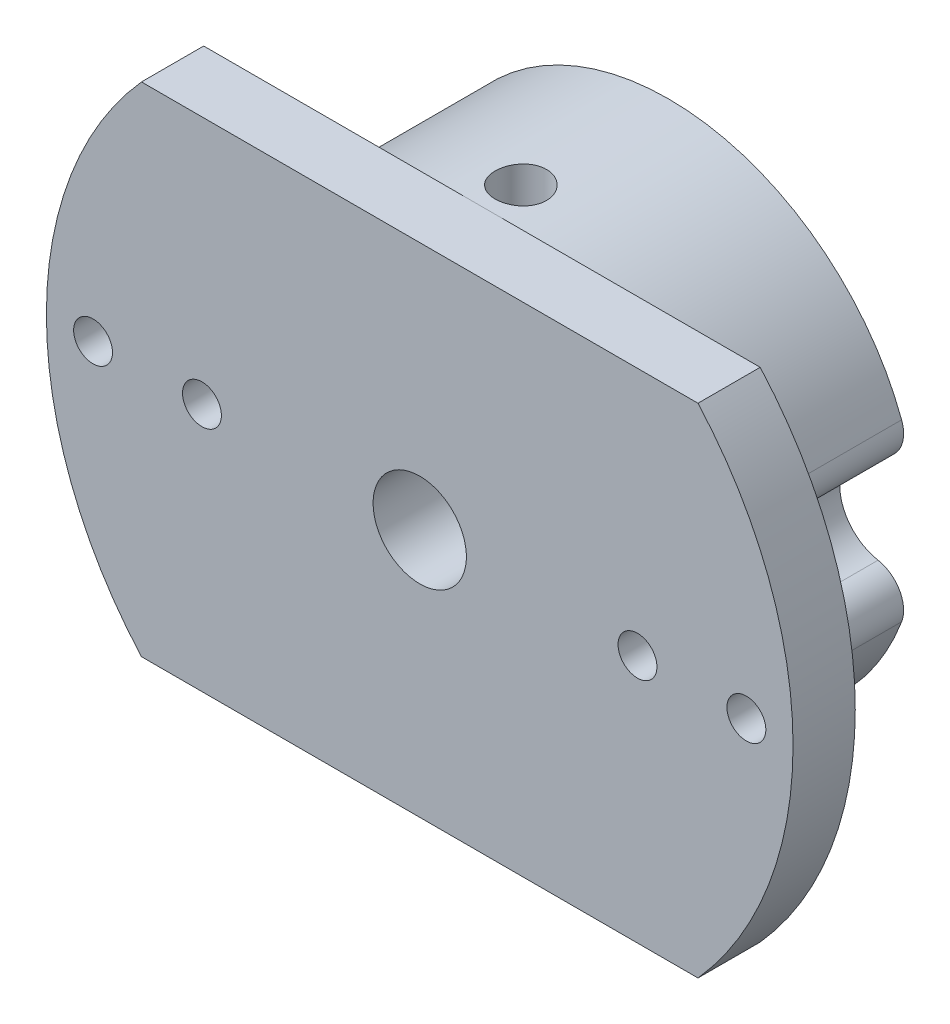
from build123d import *

# Parameters (mm, degrees)
BOSS_EXTRUDE1_DEPTH        = 4
BOSS_EXTRUDE2_REACH        = 34.985
F_2_CLEARANCE_HOLE1_D      = 2.5
F_12_CLEARANCE_HOLE1_D     = 6
F_4_CLEARANCE_HOLE1_REACH  = 43.113
F_4_CLEARANCE_HOLE1_BORE_R = 1.65
SKETCH9_W                  = 1.65
SKETCH9_H                  = 32
FILLET1_R                  = 2


with BuildPart() as part:
    # Sketch1 → Boss-Extrude1 (new body)
    with BuildSketch(Plane(origin=(0, 0, 12), x_dir=(-1, 0, 0), z_dir=(0, 0, -1))):
        with BuildLine():
            Line((-17.88854382, -16), (17.88854382, -16))
            ThreePointArc((17.88854382, -16), (24, 0), (17.88854382, 16))
            Line((17.88854382, 16), (-17.88854382, 16))
            ThreePointArc((-17.88854382, 16), (-24, 0), (-17.88854382, -16))
        make_face()
    extrude(amount=-BOSS_EXTRUDE1_DEPTH)

    # Sketch3 → Boss-Extrude2 (add, up to next)
    with BuildSketch(Plane(origin=(0, 0, 0), x_dir=(-1, 0, 0), z_dir=(0, 0, -1)), mode=Mode.PRIVATE) as boss_extrude2_sk1:
        with BuildLine():
            ThreePointArc((-15.821428571, 2.383778085), (-11, 0), (-15.821428571, -2.383778085))
            ThreePointArc((-15.821428571, -2.383778085), (0, -16), (15.821428571, -2.383778085))
            ThreePointArc((15.821428571, -2.383778085), (11, 0), (15.821428571, 2.383778085))
            ThreePointArc((15.821428571, 2.383778085), (0, 16), (-15.821428571, 2.383778085))
        make_face()
    boss_extrude2_tool1 = extrude(boss_extrude2_sk1.sketch, amount=-BOSS_EXTRUDE2_REACH, mode=Mode.PRIVATE) - part.part
    add(boss_extrude2_tool1.solids().sort_by_distance((0, 0, 0))[0])

    # #2 Clearance Hole1 (through all)
    with Locations(Plane(origin=(0, 0, 12), x_dir=(-1, 0, 0), z_dir=(0, 0, -1))):
        with Locations((21, 0), (-21, 0), (-14, 0), (14, 0)):
            Hole(F_2_CLEARANCE_HOLE1_D / 2)

    # #12 Clearance Hole1 (through all)
    with Locations(Plane(origin=(0, 0, 0), x_dir=(-1, 0, 0), z_dir=(0, 0, -1))):
        with Locations((0, 0)):
            Hole(F_12_CLEARANCE_HOLE1_D / 2)

    # #4 Clearance Hole1 bore (on position points) → #4 Clearance Hole1 (cut, up to next)
    with BuildSketch(Plane(origin=(0, 16, 9.5), x_dir=(1, 0, 0), z_dir=(0, 1, 0)), mode=Mode.PRIVATE) as f_4_clearance_hole1_sk1:
        Circle(F_4_CLEARANCE_HOLE1_BORE_R)
    f_4_clearance_hole1_tool1 = extrude(f_4_clearance_hole1_sk1.sketch, amount=-F_4_CLEARANCE_HOLE1_REACH, mode=Mode.PRIVATE) & part.part
    add(f_4_clearance_hole1_tool1.solids().sort_by_distance((0, 16, 9.5))[0], mode=Mode.SUBTRACT)

    # Sketch9 → #4 Clearance Hole2 (revolve, cut)
    with BuildSketch(Plane(origin=(0, -2.505493963, 3.5), x_dir=(0, 0, 1), z_dir=(1, 0, 0))):
        with Locations((0.825, 16)):
            Rectangle(SKETCH9_W, SKETCH9_H)
    revolve(axis=Axis((0, 3.844506037, 3.5), (0, -1, 0)), mode=Mode.SUBTRACT)

    # Fillet1
    fillet1_edges = [part.edges().sort_by_distance(p)[0] for p in [
        (15.821428571, -2.383778085, 6),
        (-15.821428571, -2.383778085, 6),
        (-15.821428571, 2.383778085, 6),
        (15.821428571, 2.383778085, 6),
    ]]
    fillet(fillet1_edges, radius=FILLET1_R)


solid = part.part
